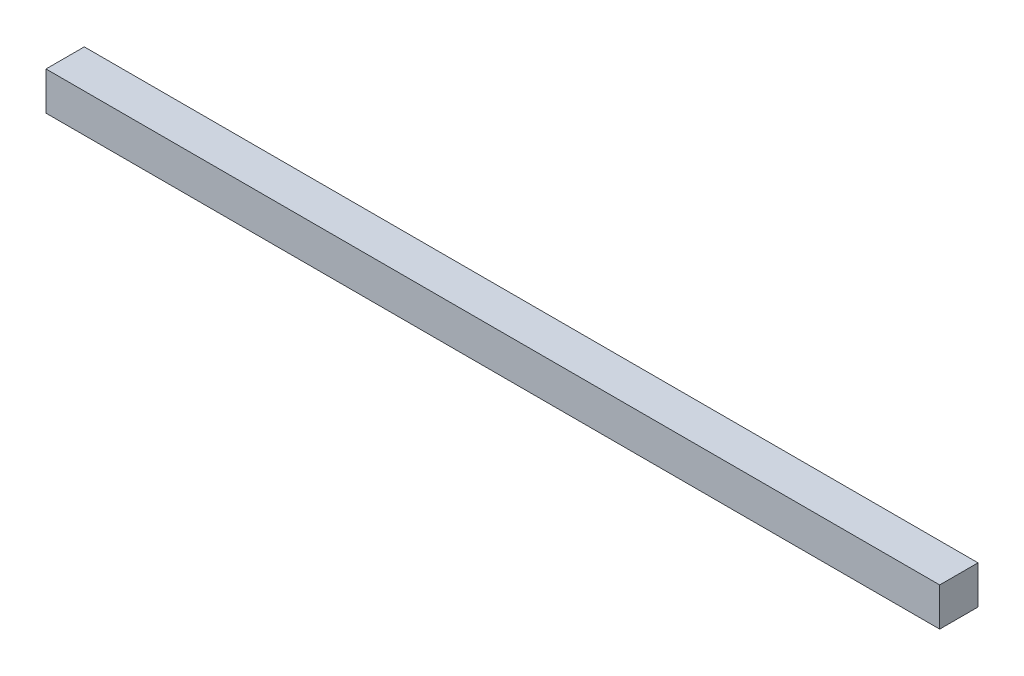
from build123d import *

# Parameters (mm, degrees)
SKETCH1_W           = 70
SKETCH1_H           = 3
BOSS_EXTRUDE1_DEPTH = 3


with BuildPart() as part:
    # Sketch1 → Boss-Extrude1 (new body)
    with BuildSketch(Plane(origin=(0, 0, 0), x_dir=(1, 0, 0), z_dir=(0, 1, 0))):
        with Locations((35, 1.5)):
            Rectangle(SKETCH1_W, SKETCH1_H)
    extrude(amount=BOSS_EXTRUDE1_DEPTH)


solid = part.part
